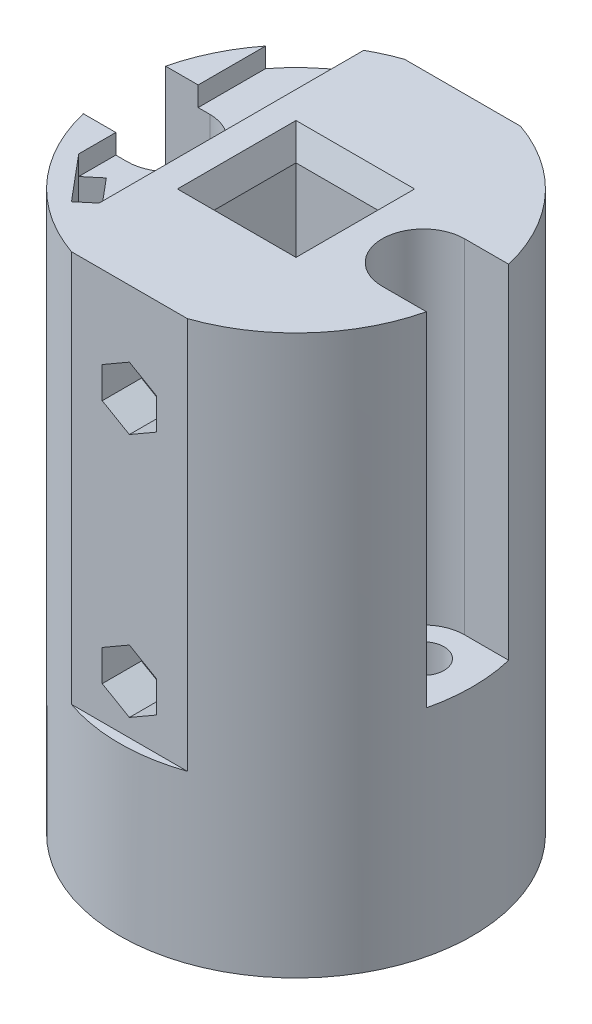
from build123d import *

# Parameters (mm, degrees)
SKETCH1_R           = 18
SKETCH1_R_2         = 2.1
SKETCH1_W           = 10.1
SKETCH1_H           = 10.1
BOSS_EXTRUDE1_DEPTH = 57
CUT_EXTRUDE4_DEPTH  = 40
SKETCH6_R           = 1.5
CUT_EXTRUDE5_DEPTH  = 36
SKETCH7_R           = 3
CUT_EXTRUDE6_DEPTH  = 3
CUT_EXTRUDE7_DEPTH  = 4
CHAMFER1_SIZE       = 1
CHAMFER1_SIZE2      = 2.747477419
CUT_EXTRUDE9_DEPTH  = 6
CHAMFER2_SIZE       = 0.5
CHAMFER2_SIZE2      = 1.37373871
CUT_EXTRUDE10_DEPTH = 35
CUT_EXTRUDE11_DEPTH = 58
CHAMFER3_SIZE       = 0.5
CHAMFER3_SIZE2      = 1.37373871
CUT_EXTRUDE13_DEPTH = 2


with BuildPart() as part:
    # Sketch1 → Boss-Extrude1 (new body)
    with BuildSketch(Plane(origin=(0, 0, 0), x_dir=(1, 0, 0), z_dir=(0, 1, 0))):
        Circle(SKETCH1_R)
        with Locations((13, 0)):
            Circle(SKETCH1_R_2, mode=Mode.SUBTRACT)
        with Locations((-13, 0)):
            Circle(SKETCH1_R_2, mode=Mode.SUBTRACT)
        Rectangle(SKETCH1_W, SKETCH1_H, mode=Mode.SUBTRACT)
    extrude(amount=BOSS_EXTRUDE1_DEPTH)

    # Sketch5 → Cut-Extrude4 (cut)
    with BuildSketch(Plane(origin=(0, 57, 0), x_dir=(1, 0, 0), z_dir=(0, 1, 0))):
        with BuildLine():
            Line((5.916079783, 17), (-5.916079783, 17))
            ThreePointArc((-5.916079783, 17), (0, 18), (5.916079783, 17))
        make_face()
        with BuildLine():
            Line((5.916079783, -17), (-5.916079783, -17))
            ThreePointArc((-5.916079783, -17), (0, -18), (5.916079783, -17))
        make_face()
    extrude(amount=-CUT_EXTRUDE4_DEPTH, mode=Mode.SUBTRACT)

    # Sketch6 → Cut-Extrude5 (cut, through all)
    with BuildSketch(Plane(origin=(0, 0, -17), x_dir=(-1, 0, 0), z_dir=(0, 0, -1))):
        with Locations((0, 47)):
            Circle(SKETCH6_R)
        with Locations((0, 22)):
            Circle(SKETCH6_R)
    extrude(amount=-CUT_EXTRUDE5_DEPTH, mode=Mode.SUBTRACT)

    # Sketch7 → Cut-Extrude6 (cut)
    with BuildSketch(Plane(origin=(0, 0, -17), x_dir=(-1, 0, 0), z_dir=(0, 0, -1))):
        with Locations((0, 47)):
            Circle(SKETCH7_R)
        with Locations((0, 22)):
            Circle(SKETCH7_R)
    extrude(amount=-CUT_EXTRUDE6_DEPTH, mode=Mode.SUBTRACT)

    # Sketch8 → Cut-Extrude7 (cut)
    with BuildSketch(Plane.XY.offset(17)):
        Polygon((0, 43.8), (2.771281292, 45.4), (2.771281292, 48.6), (0, 50.2), (-2.771281292, 48.6), (-2.771281292, 45.4), align=None)
        Polygon((0, 18.8), (2.771281292, 20.4), (2.771281292, 23.6), (0, 25.2), (-2.771281292, 23.6), (-2.771281292, 20.4), align=None)
    extrude(amount=-CUT_EXTRUDE7_DEPTH, mode=Mode.SUBTRACT)

    # Chamfer1
    chamfer1_edges = [part.edges().sort_by_distance(p)[0] for p in [
        (0, 57, -5.05),
        (-5.05, 57, 0),
        (0, 57, 5.05),
        (5.05, 57, 0),
    ]]
    chamfer1_side = [part.faces().sort_by_distance(p)[0] for p in [
        (14.267618119, 57, 10.141691708),
    ]]
    chamfer(chamfer1_edges, length=CHAMFER1_SIZE, length2=CHAMFER1_SIZE2, reference=chamfer1_side[0])

    # Sketch9 → Cut-Extrude9 (cut)
    with BuildSketch(Plane.XZ):
        with BuildLine():
            Line((15.438263477, -3.358179747), (9.406640719, -2.076118753))
            ThreePointArc((9.406640719, -2.076118753), (13.862833517, 4.059312543), (15.438263477, -3.358179747))
        make_face()
        with BuildLine():
            Line((-9.458796565, -2.163880365), (-15.354920877, -3.417140276))
            ThreePointArc((-15.354920877, -3.417140276), (-13.862833517, 4.059312543), (-9.458796565, -2.163880365))
        make_face()
    extrude(amount=-CUT_EXTRUDE9_DEPTH, mode=Mode.SUBTRACT)

    # Chamfer2
    chamfer2_edges = [part.edges().sort_by_distance(p)[0] for p in [
        (13.862833517, 0, 4.059312543),
        (12.422452098, 0, -2.71714925),
        (-13.862833517, 0, 4.059312543),
        (-12.406858721, 0, -2.79051032),
    ]]
    chamfer2_side = [part.faces().sort_by_distance(p)[0] for p in [
        (-17.490883118, 0, 0),
    ]]
    chamfer(chamfer2_edges, length=CHAMFER2_SIZE, length2=CHAMFER2_SIZE2, reference=chamfer2_side[0])

    # Sketch10 → Cut-Extrude10 (cut)
    with BuildSketch(Plane(origin=(0, 57, 0), x_dir=(1, 0, 0), z_dir=(0, 1, 0))):
        with BuildLine():
            Line((13, 4.2), (21, 4.2))
            Line((21, 4.2), (21, -4.2))
            Line((21, -4.2), (13, -4.2))
            ThreePointArc((13, -4.2), (8.8, 0), (13, 4.2))
        make_face()
        with BuildLine():
            Line((-13, 4.2), (-21, 4.2))
            Line((-21, 4.2), (-21, -4.2))
            Line((-21, -4.2), (-13, -4.2))
            ThreePointArc((-13, -4.2), (-8.8, 0), (-13, 4.2))
        make_face()
    extrude(amount=-CUT_EXTRUDE10_DEPTH, mode=Mode.SUBTRACT)

    # Sketch11 → Cut-Extrude11 (cut, through all)
    with BuildSketch(Plane.XZ):
        Polygon((-14.185073919, 7.986468426), (-10.328348261, 12.582735084), (-8.796259375, 11.297159865), (-12.652985033, 6.700893206), align=None)
    extrude(amount=-CUT_EXTRUDE11_DEPTH, mode=Mode.SUBTRACT)

    # Chamfer3
    chamfer3_edges = [part.edges().sort_by_distance(p)[0] for p in [
        (-13.419029476, 0, 7.343680816),
        (-10.724622204, 0, 8.999026536),
        (-9.562303818, 0, 11.939947475),
        (-12.25671109, 0, 10.284601755),
    ]]
    chamfer3_side = [part.faces().sort_by_distance(p)[0] for p in [
        (-17.949088312, 0, 0),
    ]]
    chamfer(chamfer3_edges, length=CHAMFER3_SIZE, length2=CHAMFER3_SIZE2, reference=chamfer3_side[0])

    # Sketch13 → Cut-Extrude13 (cut)
    with BuildSketch(Plane(origin=(0, 57, 0), x_dir=(1, 0, 0), z_dir=(0, 1, 0))):
        with BuildLine():
            Line((-8.796259375, -11.297159865), (-8.796259375, 15.704324914))
            ThreePointArc((-8.796259375, 15.704324914), (-11.720909208, 13.660903606), (-14.185073919, 11.080779662))
            Line((-14.185073919, 11.080779662), (-14.185073919, -7.986468426))
            Line((-14.185073919, -7.986468426), (-8.796259375, -11.297159865))
        make_face()
    extrude(amount=-CUT_EXTRUDE13_DEPTH, mode=Mode.SUBTRACT)


solid = part.part
